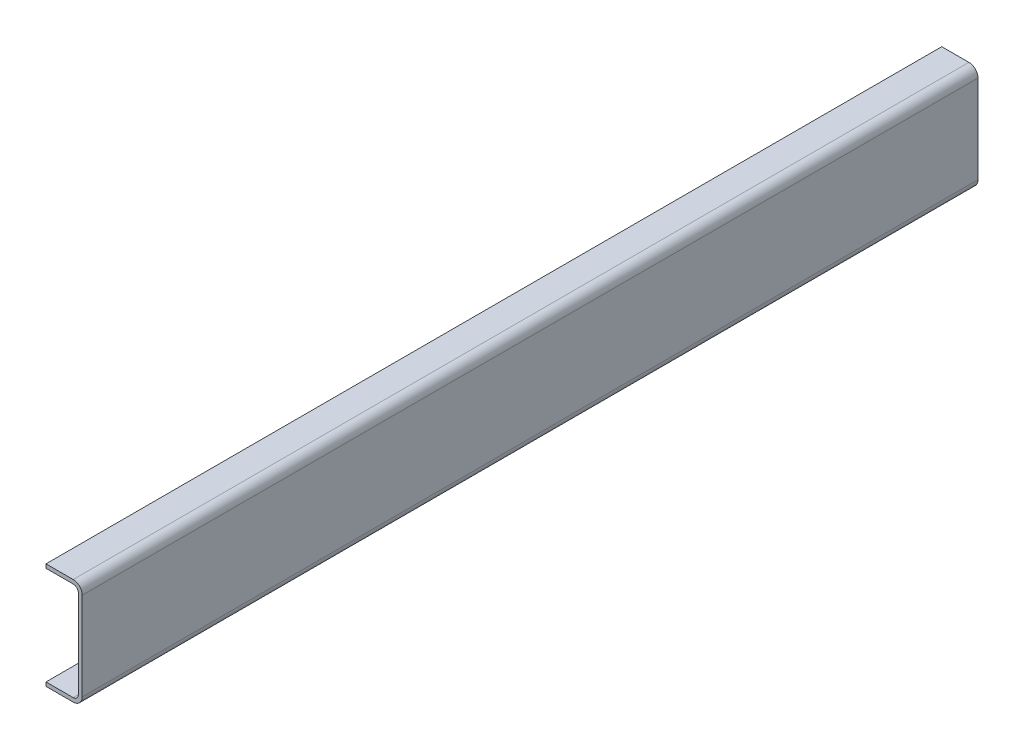
from build123d import *

# Parameters (mm, degrees)
BASE_EXTRUDE_THIN_DEPTH = 2197.1
INSIDE_BEND_RADIUS_R    = 12.7
OUTSIDE_BEND_RADIUS_R   = 22.225


with BuildPart() as part:
    # Sketch1 → Base-Extrude-Thin (new body)
    with BuildSketch(Plane.XY):
        Polygon((-88.9, 0), (0, 0), (0, 260.35), (-88.9, 260.35), (-88.9, 250.825), (-9.525, 250.825), (-9.525, 9.525), (-88.9, 9.525), align=None)
    extrude(amount=-BASE_EXTRUDE_THIN_DEPTH)

    # Inside Bend Radius
    inside_bend_radius_edges = [part.edges().sort_by_distance(p)[0] for p in [
        (-9.525, 250.825, -1098.55),
        (-9.525, 9.525, -1098.55),
    ]]
    fillet(inside_bend_radius_edges, radius=INSIDE_BEND_RADIUS_R)

    # Outside Bend Radius
    outside_bend_radius_edges = [part.edges().sort_by_distance(p)[0] for p in [
        (0, 0, -1098.55),
        (0, 260.35, -1098.55),
    ]]
    fillet(outside_bend_radius_edges, radius=OUTSIDE_BEND_RADIUS_R)


solid = part.part
